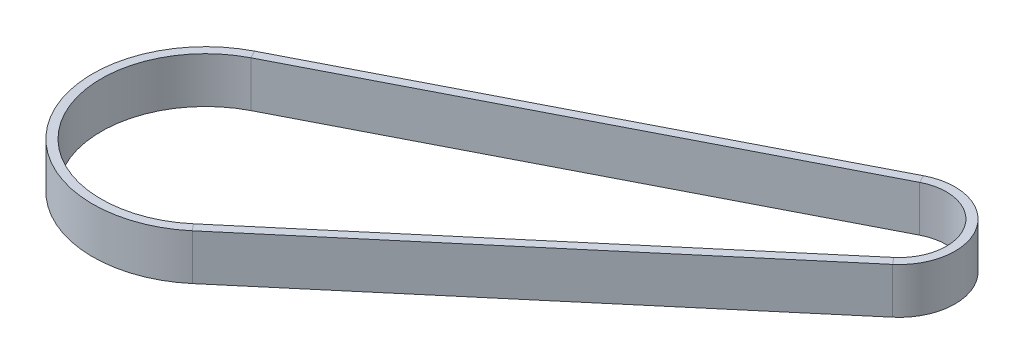
from build123d import *

# Parameters (mm, degrees)
SKETCH2_W = 3
SKETCH2_H = 16


with BuildPart() as part:
    # Sweep1: sweep along a path in Sketch1
    with BuildLine(Plane(origin=(0, 0, 0), x_dir=(1, 0, 0), z_dir=(0, 1, 0))) as sweep1_path:
        Line((-26.227685645, 550.830501906), (128.462333695, 630.052155615))
        ThreePointArc((128.462333695, 630.052155615), (151.645431275, 624.013717264), (148.296942376, 600.292284483))
        Line((148.296942376, 600.292284483), (15.645377126, 488.004107292))
        ThreePointArc((15.645377126, 488.004107292), (-40.52661613, 495.933278247), (-26.227685645, 550.830501906))
    # Sketch2 → Sweep1 (sweep)
    with BuildSketch(Plane(origin=(15.645377126, 0, -488.004107292), x_dir=(0.6460915939046579, 0, 0.7632598851542892), z_dir=(-0.7632598851542891, 0, 0.6460915939046578))):
        Rectangle(SKETCH2_W, SKETCH2_H)
    sweep(path=sweep1_path.line)


solid = part.part
